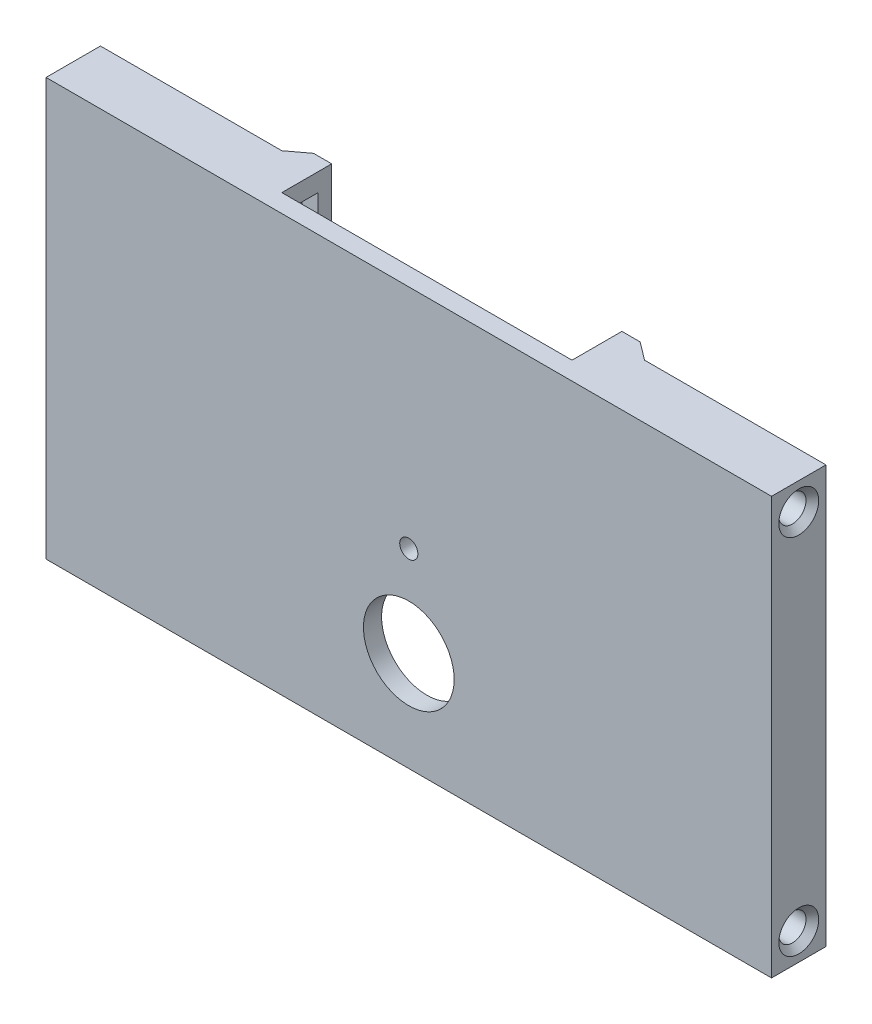
from build123d import *

# Parameters (mm, degrees)
SKIZZE1_W                               = 80
SKIZZE1_H                               = 46
SKIZZE1_R                               = 5
SKIZZE1_R_2                             = 1
AUFSATZ_LINEAR_AUSTRAGEN1_DEPTH         = 3
AUFSATZ_LINEAR_AUSTRAGEN1_DEPTH_BACK    = 3
F_3_0_3_DURCHMESSER_BOHRUNG1_AT_2_COUNT = 2
F_3_0_3_DURCHMESSER_BOHRUNG1_AT_2_PITCH = 40
SKIZZE4_W                               = 32
SKIZZE4_H                               = 46
SCHNITT_LINEAR_AUSTRAGEN1_DEPTH         = 4
SCHNITT_LINEAR_AUSTRAGEN3_DEPTH         = 4.5
SKIZZE9_W                               = 35.5
SKIZZE9_H                               = 44
SCHNITT_LINEAR_AUSTRAGEN5_DEPTH         = 2
AUFSATZ_LINEAR_AUSTRAGEN2_DEPTH         = 34
FASE1_SIZE                              = 0.7


with BuildPart() as part:
    # Skizze1 → Aufsatz-Linear austragen1 (new body, two sides)
    with BuildSketch(Plane.XY) as aufsatz_linear_austragen1_sk:
        Rectangle(SKIZZE1_W, SKIZZE1_H)
        with Locations((0, -12)):
            Circle(SKIZZE1_R, mode=Mode.SUBTRACT)
        with Locations((0, -2)):
            Circle(SKIZZE1_R_2, mode=Mode.SUBTRACT)
    extrude(amount=AUFSATZ_LINEAR_AUSTRAGEN1_DEPTH)
    extrude(aufsatz_linear_austragen1_sk.sketch, amount=-AUFSATZ_LINEAR_AUSTRAGEN1_DEPTH_BACK)

    # Skizze2 → 3.0 _3_ Durchmesser Bohrung1 (revolve, cut)
    with BuildSketch(Plane(origin=(40, -20, 0), x_dir=(0, 0, -1), z_dir=(0, 1, 0))):
        Polygon((0, 0), (0, 12.901290929), (1.5, 12), (1.5, 0), align=None)
    f_3_0_3_durchmesser_bohrung1 = revolve(axis=Axis((46.35, -20, 0), (-1, 0, 0)), mode=Mode.SUBTRACT)

    # 3.0 _3_ Durchmesser Bohrung1 at 2: 3.0 _3_ Durchmesser Bohrung1 ×2
    with Locations(*[(0, i * F_3_0_3_DURCHMESSER_BOHRUNG1_AT_2_PITCH, 0) for i in range(1, F_3_0_3_DURCHMESSER_BOHRUNG1_AT_2_COUNT)]):
        add(f_3_0_3_durchmesser_bohrung1, mode=Mode.SUBTRACT)

    # Spiegeln1: 3.0 _3_ Durchmesser Bohrung1 across plane
    add(f_3_0_3_durchmesser_bohrung1.mirror(Plane(origin=(0, 0, 0), x_dir=(0, 0, 1), z_dir=(1, 0, 0))), mode=Mode.SUBTRACT)

    # Spiegeln1 copy 1 sketch → Spiegeln1 copy 1 (revolve, cut)
    with BuildSketch(Plane(origin=(-40, 20, 0), x_dir=(0, 0, -1), z_dir=(0, 1, 0))):
        Polygon((0, 0), (0, -12.901290929), (1.5, -12), (1.5, 0), align=None)
    revolve(axis=Axis((-46.35, 20, 0), (-1, 0, 0)), mode=Mode.SUBTRACT)

    # Skizze4 → Schnitt-Linear austragen1 (cut)
    with BuildSketch(Plane.XY.offset(-3)):
        Rectangle(SKIZZE4_W, SKIZZE4_H)
    extrude(amount=SCHNITT_LINEAR_AUSTRAGEN1_DEPTH, mode=Mode.SUBTRACT)

    # Skizze6 → Schnitt-Linear austragen3 (cut)
    with BuildSketch(Plane(origin=(0, 0, -3), x_dir=(-1, 0, 0), z_dir=(0, 0, -1))):
        with BuildLine():
            Line((37, 15), (37, -15))
            ThreePointArc((37, -15), (36.414213562, -16.414213562), (35, -17))
            Line((35, -17), (22, -17))
            ThreePointArc((22, -17), (20.585786438, -16.414213562), (20, -15))
            Line((20, -15), (20, 15))
            ThreePointArc((20, 15), (20.585786438, 16.414213562), (22, 17))
            Line((22, 17), (35, 17))
            ThreePointArc((35, 17), (36.414213562, 16.414213562), (37, 15))
        make_face()
        with BuildLine():
            Line((-35, 17), (-22, 17))
            ThreePointArc((-22, 17), (-20.585786438, 16.414213562), (-20, 15))
            Line((-20, 15), (-20, -15))
            ThreePointArc((-20, -15), (-20.585786438, -16.414213562), (-22, -17))
            Line((-22, -17), (-35, -17))
            ThreePointArc((-35, -17), (-36.414213562, -16.414213562), (-37, -15))
            Line((-37, -15), (-37, 15))
            ThreePointArc((-37, 15), (-36.414213562, 16.414213562), (-35, 17))
        make_face()
    extrude(amount=-SCHNITT_LINEAR_AUSTRAGEN3_DEPTH, mode=Mode.SUBTRACT)

    # Skizze9 → Schnitt-Linear austragen5 (cut)
    with BuildSketch(Plane(origin=(0, 0, -3), x_dir=(-1, 0, 0), z_dir=(0, 0, -1))):
        with Locations((0, -1)):
            Rectangle(SKIZZE9_W, SKIZZE9_H)
    extrude(amount=-SCHNITT_LINEAR_AUSTRAGEN5_DEPTH, mode=Mode.SUBTRACT)

    # Skizze10 → Aufsatz-Linear austragen2 (add)
    with BuildSketch(Plane(origin=(0, 23, 0), x_dir=(1, 0, 0), z_dir=(0, 1, 0))):
        Polygon((-16, 3), (-16, 4.5), (-18, 4.5), (-20, 3), align=None)
        Polygon((20, 3), (16, 3), (16, 4.5), (18, 4.5), align=None)
    extrude(amount=-AUFSATZ_LINEAR_AUSTRAGEN2_DEPTH)

    # Fase1
    fase1_edges = [part.edges().sort_by_distance(p)[0] for p in [
        (40, 20, 1.5),
        (40, -20, 1.5),
        (-40, 20, 1.5),
        (-40, -20, 1.5),
    ]]
    chamfer(fase1_edges, length=FASE1_SIZE)


solid = part.part
